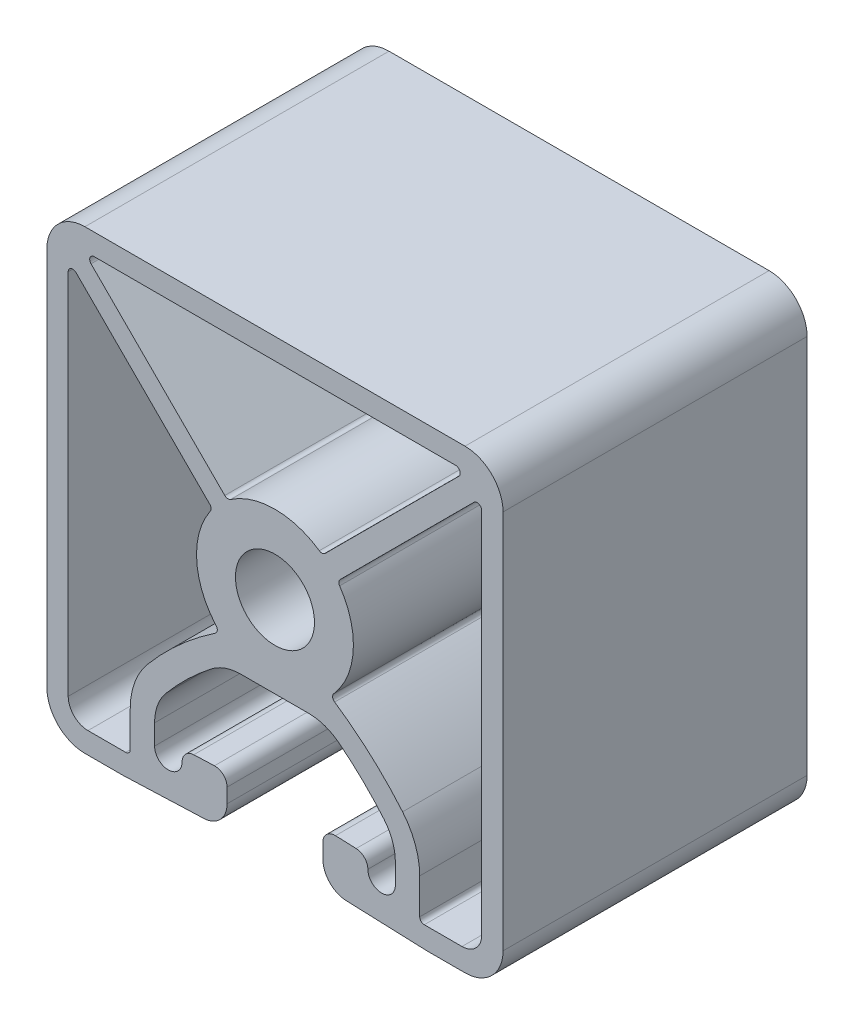
from build123d import *

# Parameters (mm, degrees)
EXTRUDE1_DEPTH = 25.4


with BuildPart() as part:
    # Sketch1 → Extrude1 (new body)
    with BuildSketch(Plane.XY):
        with BuildLine():
            Line((2.828100791, -6.8072), (0, -6.8072))
            Line((0, -6.8072), (-2.828100791, -6.8072))
            ThreePointArc((-2.828100791, -6.8072), (-4.154656747, -7.029801128), (-5.335891418, -7.673219048))
            ThreePointArc((-5.335891418, -7.673219048), (-7.314841404, -9.397406099), (-9.105295238, -11.316608824))
            ThreePointArc((-9.105295238, -11.316608824), (-9.812696364, -12.53999053), (-10.0584, -13.931647412))
            Line((-10.0584, -13.931647412), (-10.0584, -15.614648356))
            ThreePointArc((-10.0584, -15.614648356), (-8.91004969, -16.763999564), (-7.759698458, -15.616651022))
            ThreePointArc((-7.759698458, -15.616651022), (-7.475165883, -14.913287543), (-6.782702014, -14.603170209))
            Line((-6.782702014, -14.603170209), (-5.055502014, -14.536817878))
            ThreePointArc((-5.055502014, -14.536817878), (-4.312003742, -14.819989072), (-4.0005, -15.552069001))
            Line((-4.0005, -15.552069001), (-4.0005, -16.760361628))
            ThreePointArc((-4.0005, -16.760361628), (-4.568340141, -18.169354143), (-5.954495972, -18.790863874))
            Line((-5.954495972, -18.790863874), (-12.7, -19.05))
            Line((-12.7, -19.05), (-15.875, -19.05))
            ThreePointArc((-15.875, -19.05), (-18.12006403, -18.12006403), (-19.05, -15.875))
            Line((-19.05, -15.875), (-19.05, 15.875))
            ThreePointArc((-19.05, 15.875), (-18.12006403, 18.12006403), (-15.875, 19.05))
            Line((-15.875, 19.05), (0, 19.05))
            Line((0, 19.05), (15.875, 19.05))
            ThreePointArc((15.875, 19.05), (18.12006403, 18.12006403), (19.05, 15.875))
            Line((19.05, 15.875), (19.05, -15.875))
            ThreePointArc((19.05, -15.875), (18.12006403, -18.12006403), (15.875, -19.05))
            Line((15.875, -19.05), (12.7, -19.05))
            Line((12.7, -19.05), (5.954495972, -18.790863874))
            ThreePointArc((5.954495972, -18.790863874), (4.568340141, -18.169354143), (4.0005, -16.760361628))
            Line((4.0005, -16.760361628), (4.0005, -15.552069001))
            ThreePointArc((4.0005, -15.552069001), (4.312003742, -14.819989072), (5.055502014, -14.536817878))
            Line((5.055502014, -14.536817878), (6.782702014, -14.603170209))
            ThreePointArc((6.782702014, -14.603170209), (7.475165883, -14.913287543), (7.759698458, -15.616651022))
            ThreePointArc((7.759698458, -15.616651022), (8.91004969, -16.763999564), (10.0584, -15.614648356))
            Line((10.0584, -15.614648356), (10.0584, -13.931647412))
            ThreePointArc((10.0584, -13.931647412), (9.812696364, -12.53999053), (9.105295238, -11.316608824))
            ThreePointArc((9.105295238, -11.316608824), (7.314841404, -9.397406099), (5.335891418, -7.673219048))
            ThreePointArc((5.335891418, -7.673219048), (4.154656747, -7.029801128), (2.828100791, -6.8072))
        make_face()
        with BuildLine():
            Line((4.191663684, 5.448899541), (15.364356459, 16.621592316))
            ThreePointArc((15.364356459, 16.621592316), (15.446946878, 17.036802388), (15.094948776, 17.272))
            Line((15.094948776, 17.272), (0, 17.272))
            Line((0, 17.272), (-15.094948776, 17.272))
            ThreePointArc((-15.094948776, 17.272), (-15.446946878, 17.036802388), (-15.364356459, 16.621592316))
            Line((-15.364356459, 16.621592316), (-4.191663684, 5.448899541))
            ThreePointArc((-4.191663684, 5.448899541), (-3.957294594, 5.338921804), (-3.706747429, 5.40411452))
            ThreePointArc((-3.706747429, 5.40411452), (-1.940384881, 6.259339962), (0, 6.5532))
            ThreePointArc((0, 6.5532), (1.940384881, 6.259339962), (3.706747429, 5.40411452))
            ThreePointArc((3.706747429, 5.40411452), (3.957294594, 5.338921804), (4.191663684, 5.448899541))
        make_face(mode=Mode.SUBTRACT)
        with BuildLine():
            Line((-17.272, 15.094948776), (-17.272, -15.621))
            ThreePointArc((-17.272, -15.621), (-16.788433296, -16.788433296), (-15.621, -17.272))
            Line((-15.621, -17.272), (-12.4714, -17.272))
            ThreePointArc((-12.4714, -17.272), (-12.201992316, -17.160407684), (-12.0904, -16.891))
            Line((-12.0904, -16.891), (-12.0904, -13.931647412))
            ThreePointArc((-12.0904, -13.931647412), (-11.721844546, -11.84416209), (-10.660742857, -10.00908953))
            ThreePointArc((-10.660742857, -10.00908953), (-8.000870719, -7.259428949), (-4.984332303, -4.906547928))
            ThreePointArc((-4.984332303, -4.906547928), (-4.819224111, -4.638901343), (-4.91158257, -4.338293085))
            ThreePointArc((-4.91158257, -4.338293085), (-6.540953358, -0.40044901), (-5.40411452, 3.706747429))
            ThreePointArc((-5.40411452, 3.706747429), (-5.338921804, 3.957294594), (-5.448899541, 4.191663684))
            Line((-5.448899541, 4.191663684), (-16.621592316, 15.364356459))
            ThreePointArc((-16.621592316, 15.364356459), (-17.036802388, 15.446946878), (-17.272, 15.094948776))
        make_face(mode=Mode.SUBTRACT)
        with BuildLine():
            Line((17.272, 15.094948776), (17.272, -15.621))
            ThreePointArc((17.272, -15.621), (16.788433296, -16.788433296), (15.621, -17.272))
            Line((15.621, -17.272), (12.4714, -17.272))
            ThreePointArc((12.4714, -17.272), (12.201992316, -17.160407684), (12.0904, -16.891))
            Line((12.0904, -16.891), (12.0904, -13.931647412))
            ThreePointArc((12.0904, -13.931647412), (11.721844546, -11.84416209), (10.660742857, -10.00908953))
            ThreePointArc((10.660742857, -10.00908953), (8.000870719, -7.259428949), (4.984332303, -4.906547928))
            ThreePointArc((4.984332303, -4.906547928), (4.819224111, -4.638901343), (4.91158257, -4.338293085))
            ThreePointArc((4.91158257, -4.338293085), (6.540953358, -0.40044901), (5.40411452, 3.706747429))
            ThreePointArc((5.40411452, 3.706747429), (5.338921804, 3.957294594), (5.448899541, 4.191663684))
            Line((5.448899541, 4.191663684), (16.621592316, 15.364356459))
            ThreePointArc((16.621592316, 15.364356459), (17.036802388, 15.446946878), (17.272, 15.094948776))
        make_face(mode=Mode.SUBTRACT)
        with BuildLine():
            ThreePointArc((0, 3.302), (-3.302, 0), (0, -3.302))
            ThreePointArc((0, -3.302), (3.302, 0), (0, 3.302))
        make_face(mode=Mode.SUBTRACT)
    extrude(amount=EXTRUDE1_DEPTH)


solid = part.part
